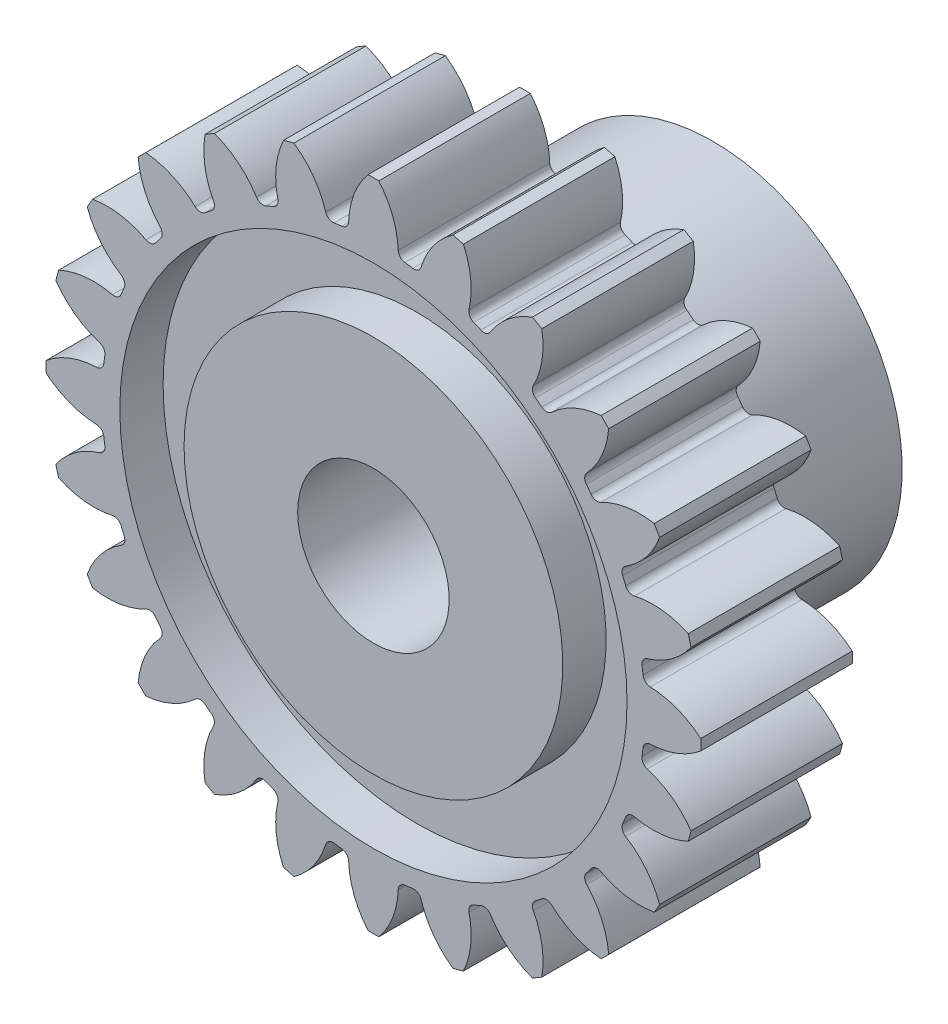
from build123d import *

# Parameters (mm, degrees)
CUT_EXTRUDE1_START = -15.224
CUT_EXTRUDE1_DEPTH = 16.224
CIRPATTERN1_COUNT  = 24


with BuildPart() as part:
    # Sketch3 → Revolve1 (revolve)
    with BuildSketch(Plane(origin=(0, 0, 0), x_dir=(0, 0, -1), z_dir=(1, 0, 0))):
        Polygon((-7.112, 13.72235), (-0.762, 13.72235), (-0.762, 10.6299), (-2.576285714, 10.6299), (-2.576285714, 7.9375), (7.112, 7.9375), (7.112, 3.175), (-7.112, 3.175), (-7.112, 7.9375), (-5.297714286, 7.9375), (-5.297714286, 10.6299), (-7.112, 10.6299), align=None)
    revolve(axis=Axis((0, 0, -7.112), (0, 0, 1)))

    # Sketch4 → Cut-Extrude1 (cut)
    with BuildSketch(Plane.XY.offset(7.112).offset(CUT_EXTRUDE1_START)):
        with BuildLine():
            ThreePointArc((-0.226165225, 13.7204861), (-0.809623795, 12.730495659), (-1.039023964, 11.604493643))
            ThreePointArc((-1.039023964, 11.604493643), (-1.122909631, 11.400437837), (-1.319504028, 11.300306823))
            ThreePointArc((-1.319504028, 11.300306823), (-1.485007366, 11.279750808), (-1.650191603, 11.256770978))
            ThreePointArc((-1.650191603, 11.256770978), (-1.866003022, 11.302607737), (-1.999843883, 11.477999301))
            ThreePointArc((-1.999843883, 11.477999301), (-2.512858197, 12.506260596), (-3.332664279, 13.311507741))
            ThreePointArc((-3.332664279, 13.311507741), (-1.791126094, 13.604953393), (-0.226165225, 13.7204861))
        make_face()
    cut_extrude1 = extrude(amount=CUT_EXTRUDE1_DEPTH, mode=Mode.SUBTRACT)

    # CirPattern1: Cut-Extrude1 ×24 about axis
    cirpattern1_axis = Axis((0, 0, 0), (0, 0, 1))
    for i in range(1, CIRPATTERN1_COUNT):
        add(cut_extrude1.rotate(cirpattern1_axis, i * 360 / CIRPATTERN1_COUNT), mode=Mode.SUBTRACT)


solid = part.part
